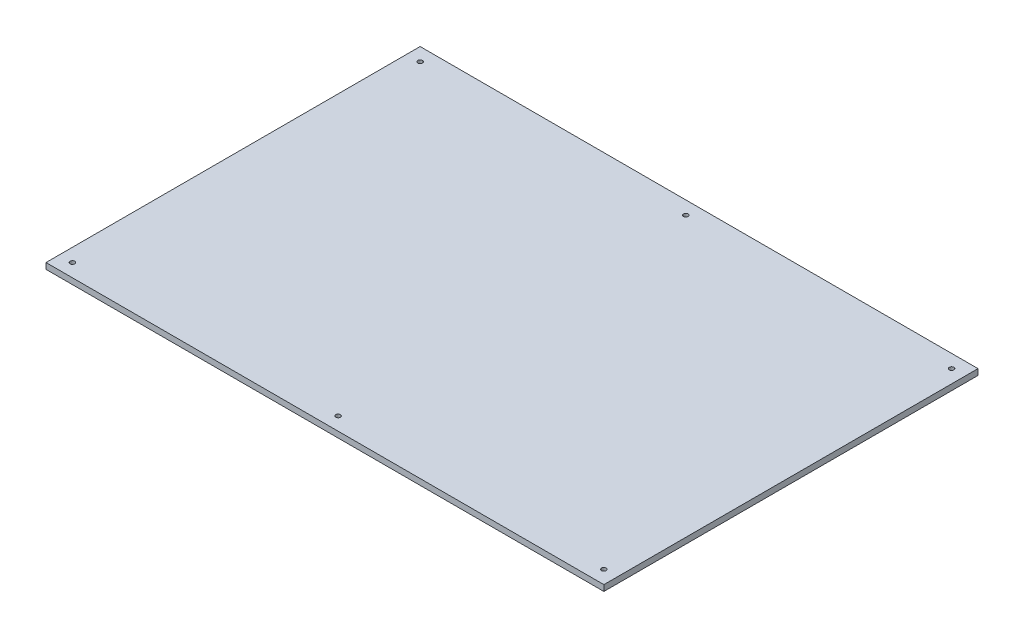
from build123d import *

# Parameters (mm, degrees)
SKETCH1_W               = 422
SKETCH1_H               = 283
BOSS_EXTRUDE1_DEPTH     = 4.5
SKETCH2_R               = 1.75
CUT_EXTRUDE1_DEPTH      = 4.5
MIRROR3_COPY_1_SKETCH_R = 1.75
MIRROR3_COPY_1_DEPTH    = 4.5


with BuildPart() as part:
    # Sketch1 → Boss-Extrude1 (new body)
    with BuildSketch(Plane(origin=(0, 0, 0), x_dir=(1, 0, 0), z_dir=(0, 1, 0))):
        Rectangle(SKETCH1_W, SKETCH1_H)
    extrude(amount=BOSS_EXTRUDE1_DEPTH)

    # Sketch2 → Cut-Extrude1 (cut)
    with BuildSketch(Plane(origin=(0, 4.5, 0), x_dir=(1, 0, 0), z_dir=(0, 1, 0))):
        with Locations((-201, 131.5)):
            Circle(SKETCH2_R)
        with Locations((0, 131.5)):
            Circle(SKETCH2_R)
    cut_extrude1 = extrude(amount=-CUT_EXTRUDE1_DEPTH, mode=Mode.SUBTRACT)

    # Mirror2: Cut-Extrude1 across plane
    add(cut_extrude1.mirror(Plane(origin=(0, 0, 0), x_dir=(0, 0, 1), z_dir=(1, 0, 0))), mode=Mode.SUBTRACT)

    # Mirror3: Cut-Extrude1 across plane
    add(cut_extrude1.mirror(Plane.XY), mode=Mode.SUBTRACT)

    # Mirror3 copy 1 sketch → Mirror3 copy 1 (cut)
    with BuildSketch(Plane(origin=(0, 4.5, 0), x_dir=(-1, 0, 0), z_dir=(0, 1, 0))):
        with Locations((-201, 131.5)):
            Circle(MIRROR3_COPY_1_SKETCH_R)
        with Locations((0, 131.5)):
            Circle(MIRROR3_COPY_1_SKETCH_R)
    extrude(amount=-MIRROR3_COPY_1_DEPTH, mode=Mode.SUBTRACT)


solid = part.part
